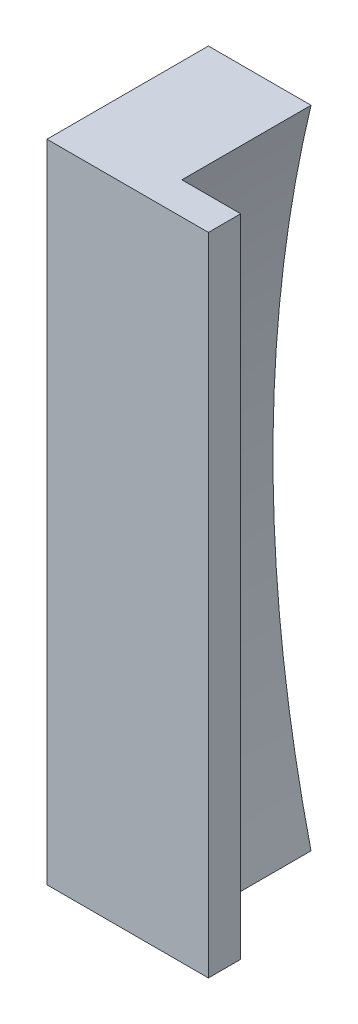
from build123d import *

# Parameters (mm, degrees)
BOSS_EXTRU_1_DEPTH                                 = 20
ESQUISSE9_W                                        = 25
ESQUISSE9_H                                        = 100
BOSS_EXTRU_2_DEPTH                                 = 5
CHAMBRAGE_POUR_VIS_T_TE_HEXAGONALE_M53_D           = 5.5
CHAMBRAGE_POUR_VIS_T_TE_HEXAGONALE_M53_CBORE_D     = 10
CHAMBRAGE_POUR_VIS_T_TE_HEXAGONALE_M53_CBORE_DEPTH = 5
CHAMBRAGE_POUR_VIS_T_TE_HEXAGONALE_M54_D           = 5.5
CHAMBRAGE_POUR_VIS_T_TE_HEXAGONALE_M54_CBORE_D     = 10
CHAMBRAGE_POUR_VIS_T_TE_HEXAGONALE_M54_CBORE_DEPTH = 5
TROU_TARAUD_M52_D                                  = 4.2


with BuildPart() as part:
    # Esquisse1 → Boss.-Extru.1 (new body)
    with BuildSketch(Plane.XY):
        with BuildLine():
            Line((-225, 50), (-225, -50))
            Line((-225, -50), (-209.105236663, -50))
            ThreePointArc((-209.105236663, -50), (-215, 0), (-209.105236663, 50))
            Line((-209.105236663, 50), (-225, 50))
        make_face()
    extrude(amount=BOSS_EXTRU_1_DEPTH)

    # Esquisse9 → Boss.-Extru.2 (add)
    with BuildSketch(Plane.XY.offset(20)):
        with Locations((-212.5, 0)):
            Rectangle(ESQUISSE9_W, ESQUISSE9_H)
    extrude(amount=BOSS_EXTRU_2_DEPTH)

    # Chambrage pour vis à tête hexagonale M53 (through all)
    with Locations(Plane.ZY.offset(225)):
        with Locations((16, 35)):
            CounterBoreHole(CHAMBRAGE_POUR_VIS_T_TE_HEXAGONALE_M53_D / 2, CHAMBRAGE_POUR_VIS_T_TE_HEXAGONALE_M53_CBORE_D / 2, CHAMBRAGE_POUR_VIS_T_TE_HEXAGONALE_M53_CBORE_DEPTH)

    # Chambrage pour vis à tête hexagonale M54 (through all)
    with Locations(Plane.ZY.offset(225)):
        with Locations((16, -35)):
            CounterBoreHole(CHAMBRAGE_POUR_VIS_T_TE_HEXAGONALE_M54_D / 2, CHAMBRAGE_POUR_VIS_T_TE_HEXAGONALE_M54_CBORE_D / 2, CHAMBRAGE_POUR_VIS_T_TE_HEXAGONALE_M54_CBORE_DEPTH)

    # Trou taraudé M52 (through all)
    with Locations(Plane.ZY.offset(225)):
        with Locations((12.5, 20), (12.5, -20)):
            Hole(TROU_TARAUD_M52_D / 2)


solid = part.part
